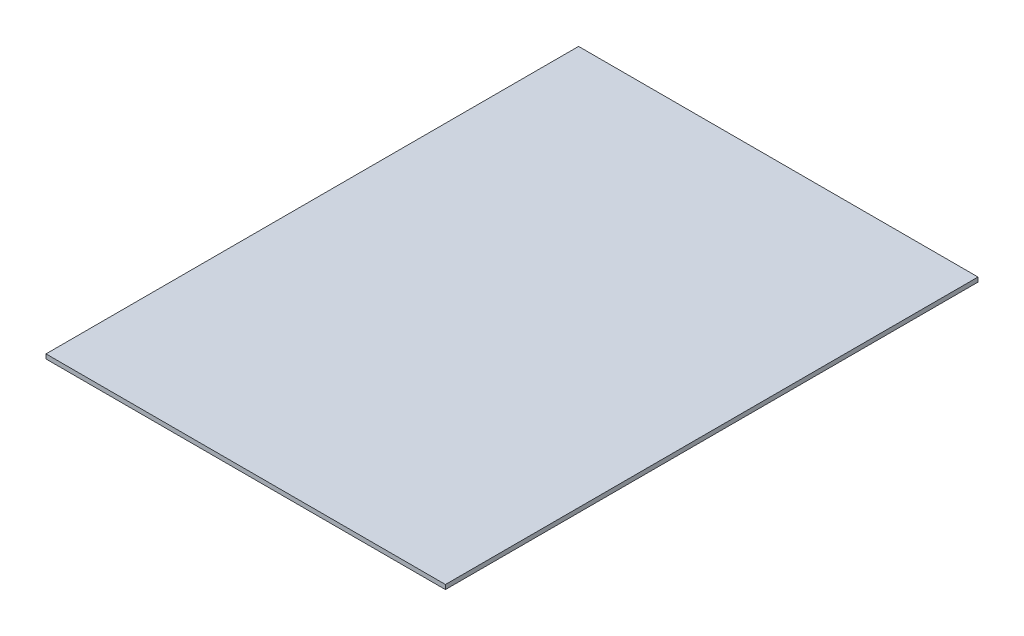
from build123d import *

# Parameters (mm, degrees)
SKETCH1_W           = 90
SKETCH1_H           = 120
BOSS_EXTRUDE1_DEPTH = 1


with BuildPart() as part:
    # Sketch1 → Boss-Extrude1 (new body)
    with BuildSketch(Plane(origin=(0, 0, 0), x_dir=(1, 0, 0), z_dir=(0, 1, 0))):
        Rectangle(SKETCH1_W, SKETCH1_H)
    extrude(amount=BOSS_EXTRUDE1_DEPTH)


solid = part.part
